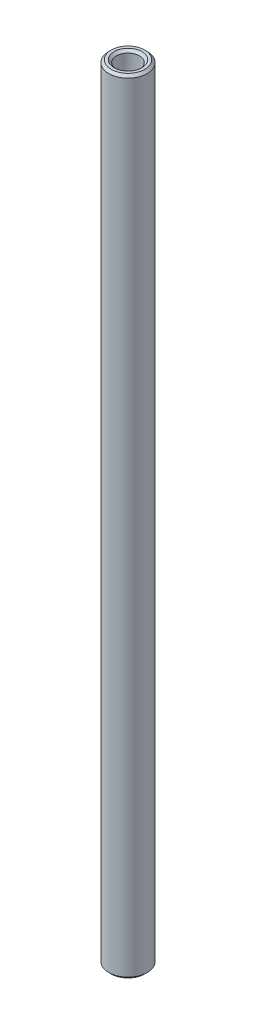
from build123d import *

# Parameters (mm, degrees)
SKETCH1_R           = 1.984375
SKETCH1_R_2         = 1.190625
BOSS_EXTRUDE1_DEPTH = 40.48125
CHAMFER1_SIZE       = 0.254


with BuildPart() as part:
    # Sketch1 → Boss-Extrude1 (new body, symmetric)
    with BuildSketch(Plane(origin=(0, 0, 0), x_dir=(1, 0, 0), z_dir=(0, 1, 0))):
        Circle(SKETCH1_R)
        Circle(SKETCH1_R_2, mode=Mode.SUBTRACT)
    extrude(amount=BOSS_EXTRUDE1_DEPTH, both=True)

    # Chamfer1
    chamfer1_edges = [part.edges().sort_by_distance(p)[0] for p in [
        (-1.984375, -40.48125, 0),
        (-1.984375, 40.48125, 0),
        (-1.190625, -40.48125, 0),
        (-1.190625, 40.48125, 0),
    ]]
    chamfer(chamfer1_edges, length=CHAMFER1_SIZE)


solid = part.part
